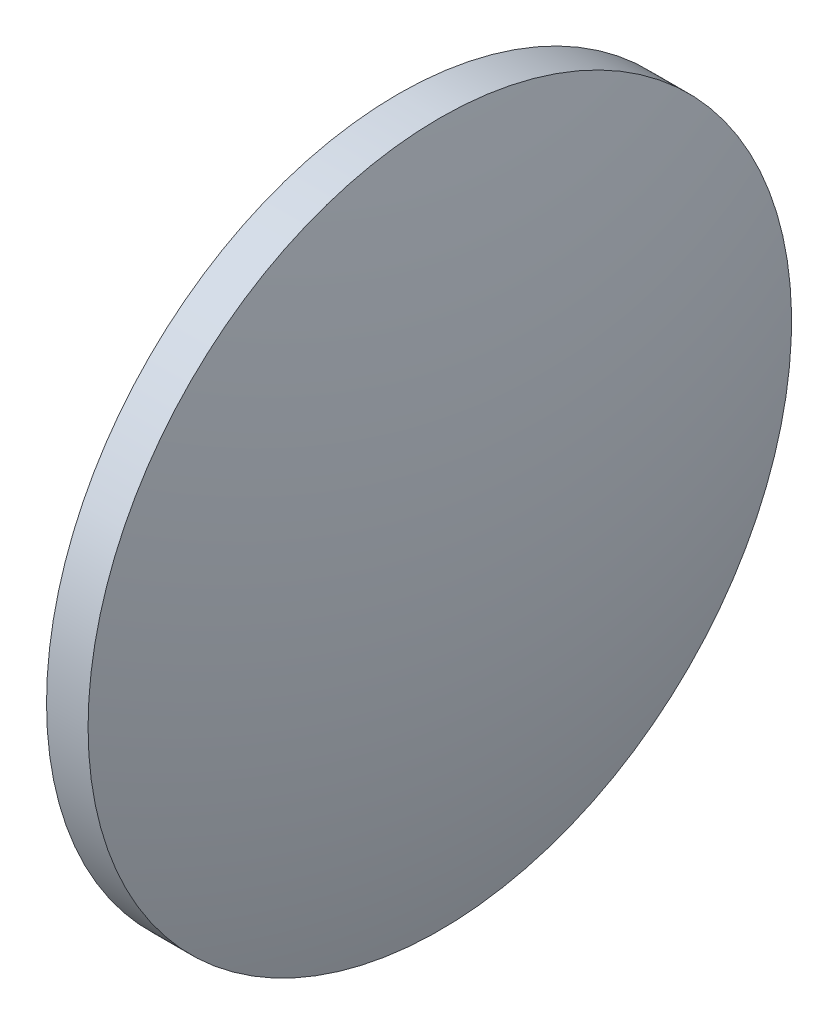
from build123d import *

# Parameters (mm, degrees)
SKETCH_1_ONE_SIDE_W = 2.999957714
SKETCH_1_ONE_SIDE_H = 25.4


with BuildPart() as part:
    # 草图1 one side → 旋转1 (revolve)
    with BuildSketch(Plane.XY):
        with Locations((172.916387549, 109.932226046)):
            Rectangle(SKETCH_1_ONE_SIDE_W, SKETCH_1_ONE_SIDE_H)
        with BuildLine():
            Line((167.766392406, 97.232226046), (171.416408692, 97.232226046))
            Line((171.416408692, 97.232226046), (171.416408692, 122.632226046))
            ThreePointArc((171.416408692, 122.632226046), (168.683559282, 110.062684133), (167.766392406, 97.232226046))
        make_face()
        with BuildLine():
            Line((174.416366406, 97.232226046), (178.066382692, 97.232226046))
            ThreePointArc((178.066382692, 97.232226046), (177.149215816, 110.062684133), (174.416366406, 122.632226046))
            Line((174.416366406, 122.632226046), (174.416366406, 97.232226046))
        make_face()
    revolve(axis=Axis((165.744107942, 97.232226046, 0), (1, 0, 0)))


solid = part.part
